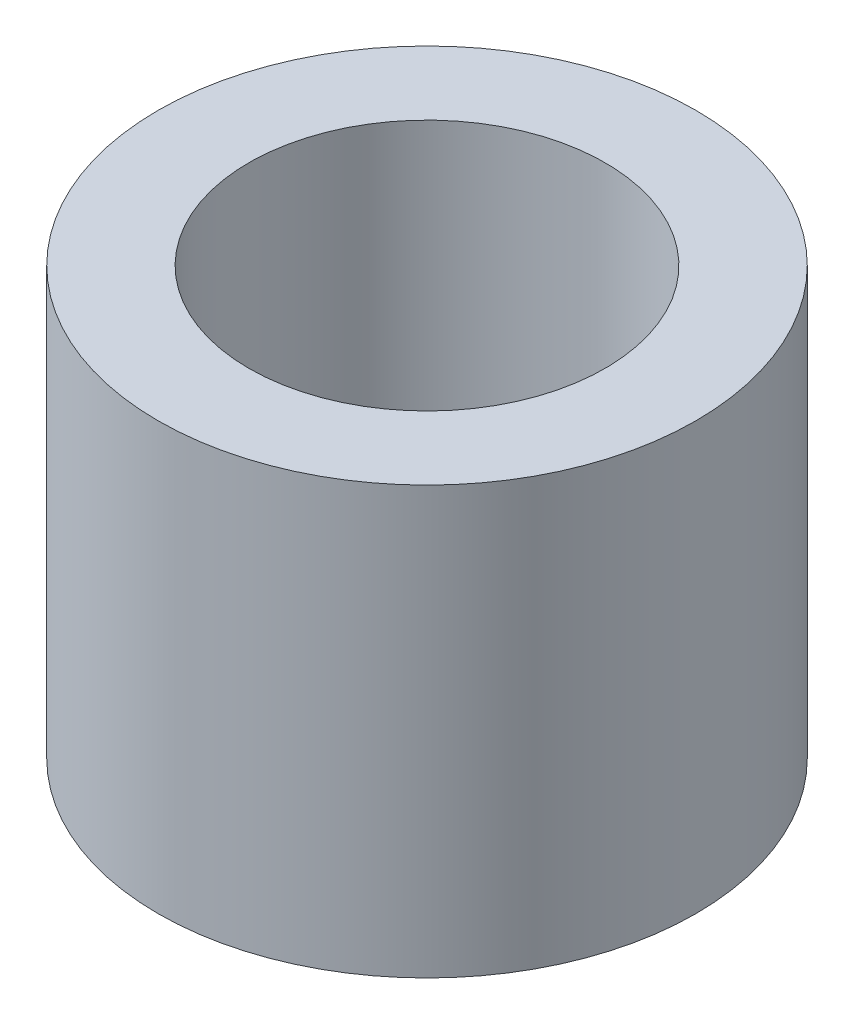
from build123d import *

# Parameters (mm, degrees)
CROQUIS1_R              = 4
CROQUIS1_R_2            = 2.65
SALIENTE_EXTRUIR1_DEPTH = 6.35


with BuildPart() as part:
    # Croquis1 → Saliente-Extruir1 (new body)
    with BuildSketch(Plane(origin=(0, 0, 0), x_dir=(1, 0, 0), z_dir=(0, 1, 0))):
        Circle(CROQUIS1_R)
        Circle(CROQUIS1_R_2, mode=Mode.SUBTRACT)
    extrude(amount=SALIENTE_EXTRUIR1_DEPTH)


solid = part.part
